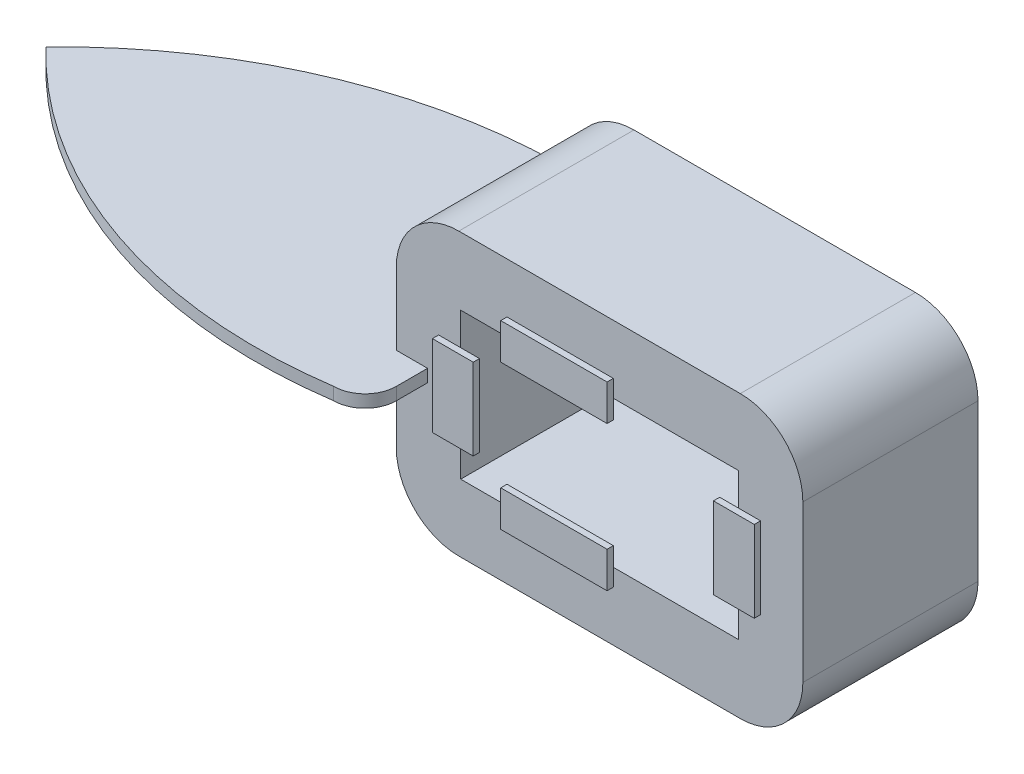
from build123d import *

# Parameters (mm, degrees)
SKETCH_1_W           = 65
SKETCH_1_H           = 45
EXTRUDE_1_DEPTH      = 28
SKETCH_2_W           = 44.4
SKETCH_2_H           = 23.4
CUT_EXTRUDE_1_DEPTH  = 39
FILLET_1_R           = 10
FILLET_2_R           = 10
FILLET_3_R           = 10
FILLET_4_R           = 10
EXTRUDE_6_DEPTH      = 1
EXTRUDE_6_2_DEPTH    = 1
EXTRUDE_6_3_DEPTH    = 1
SKETCH_10_W          = 17
SKETCH_10_H          = 5.754584259
EXTRUDE_6_4_DEPTH    = 1
SKETCH_20_W          = 5.002637397
SKETCH_20_H          = 2
EXTRUDE_7_DEPTH      = 10
SKETCH_21_W          = 5.00232547
SKETCH_21_H          = 2
EXTRUDE_8_DEPTH      = 10
EXTRUDE_9_DEPTH      = 1
EXTRUDE_9_DEPTH_BACK = 1
FILLET_5_R           = 5
FILLET_6_R           = 5


with BuildPart() as part:
    # 草圖1 → 填料-伸長1 (new body)
    with BuildSketch(Plane.XY):
        with Locations((-27.434655272, 0)):
            Rectangle(SKETCH_1_W, SKETCH_1_H)
    extrude(amount=EXTRUDE_1_DEPTH)

    # 草圖2 → 除料-伸長1 (cut)
    with BuildSketch(Plane.XY):
        with Locations((-27.434655272, 0)):
            Rectangle(SKETCH_2_W, SKETCH_2_H)
    extrude(amount=CUT_EXTRUDE_1_DEPTH, mode=Mode.SUBTRACT)

    # 圓角1
    fillet_1_edges = [part.edges().sort_by_distance(p)[0] for p in [
        (-59.934655272, -22.5, 14),
    ]]
    fillet(fillet_1_edges, radius=FILLET_1_R)

    # 圓角2
    fillet_2_edges = [part.edges().sort_by_distance(p)[0] for p in [
        (-59.934655272, 22.5, 14),
    ]]
    fillet(fillet_2_edges, radius=FILLET_2_R)

    # 圓角3
    fillet_3_edges = [part.edges().sort_by_distance(p)[0] for p in [
        (5.065344728, 22.5, 14),
    ]]
    fillet(fillet_3_edges, radius=FILLET_3_R)

    # 圓角4
    fillet_4_edges = [part.edges().sort_by_distance(p)[0] for p in [
        (5.065344728, -22.5, 14),
    ]]
    fillet(fillet_4_edges, radius=FILLET_4_R)

    # 草圖20 → 填料-伸長7 (add)
    with BuildSketch(Plane.XY.offset(28)):
        with Locations((-57.433336574, 0)):
            Rectangle(SKETCH_20_W, SKETCH_20_H)
    extrude(amount=EXTRUDE_7_DEPTH)

    # 草圖21 → 填料-伸長8 (add)
    with BuildSketch(Plane(origin=(0, 0, 0), x_dir=(-1, 0, 0), z_dir=(0, 0, -1))):
        with Locations((57.433492537, 0)):
            Rectangle(SKETCH_21_W, SKETCH_21_H)
    extrude(amount=EXTRUDE_8_DEPTH)

    # 草圖22 → 填料-伸長9 (add, two sides)
    with BuildSketch(Plane(origin=(0, 0, 0), x_dir=(1, 0, 0), z_dir=(0, 1, 0))) as extrude_9_sk:
        with BuildLine():
            Line((-59.934655272, 10), (-59.934655272, -38))
            ThreePointArc((-59.934655272, -38), (-97.835563119, -34.46098122), (-129.934655272, -14))
            ThreePointArc((-129.934655272, -14), (-97.835563119, 6.46098122), (-59.934655272, 10))
        make_face()
    extrude(amount=EXTRUDE_9_DEPTH)
    extrude(extrude_9_sk.sketch, amount=-EXTRUDE_9_DEPTH_BACK)

    # 圓角5
    fillet_5_edges = [part.edges().sort_by_distance(p)[0] for p in [
        (-54.932329802, 0, -10),
    ]]
    fillet(fillet_5_edges, radius=FILLET_5_R)

    # 圓角6
    fillet_6_edges = [part.edges().sort_by_distance(p)[0] for p in [
        (-54.932017875, 0, 38),
    ]]
    fillet(fillet_6_edges, radius=FILLET_6_R)


with BuildPart() as body_2:
    # 草圖10 → 填料-伸長6 (new body)
    with BuildSketch(Plane.XY.offset(29)):
        Polygon((-49.634655272, 6.5), (-53.165057103, 6.5), (-53.165057103, -6.5), (-46.634655272, -6.5), (-46.634655272, 6.5), align=None)
    extrude(amount=-EXTRUDE_6_DEPTH)


with BuildPart() as body_3:
    # 草圖10 → Extrude 6 2 (new body)
    with BuildSketch(Plane.XY.offset(29)):
        Polygon((-42.234655272, -11.7), (-42.234655272, -8.7), (-25.234655272, -8.7), (-25.234655272, -14.454584259), (-42.234655272, -14.454584259), align=None)
    extrude(amount=-EXTRUDE_6_2_DEPTH)


with BuildPart() as body_4:
    # 草圖10 → Extrude 6 3 (new body)
    with BuildSketch(Plane.XY.offset(29)):
        Polygon((-8.234655272, 6.5), (-8.234655272, -6.5), (-5.234655272, -6.5), (-1.70425344, -6.5), (-1.70425344, 6.5), align=None)
    extrude(amount=-EXTRUDE_6_3_DEPTH)


with BuildPart() as body_5:
    # 草圖10 → Extrude 6 4 (new body)
    with BuildSketch(Plane.XY.offset(29)):
        with Locations((-33.734655272, 11.57729213)):
            Rectangle(SKETCH_10_W, SKETCH_10_H)
    extrude(amount=-EXTRUDE_6_4_DEPTH)


solid = Compound([part.part, body_2.part, body_3.part, body_4.part, body_5.part])
